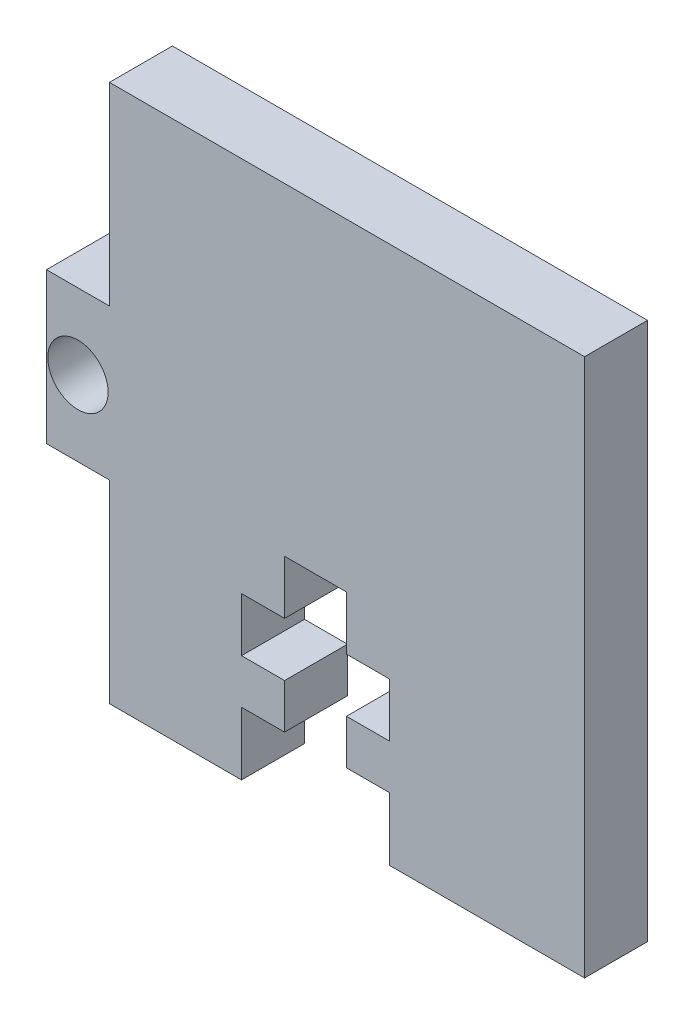
from build123d import *

# Parameters (mm, degrees)
SKETCH1_R           = 1.4224
BOSS_EXTRUDE1_DEPTH = 2.9718


with BuildPart() as part:
    # Sketch1 → Boss-Extrude1 (new body)
    with BuildSketch(Plane.XY):
        Polygon((25.4, 25.4), (2.9718, 25.4), (2.9718, 16.256), (0, 16.256), (0, 9.144), (2.9718, 9.144), (2.9718, 0), (9.2075, 0), (9.2075, 2.9718), (11.2395, 2.9718), (11.2395, 5.08), (9.2075, 5.08), (9.2075, 7.62), (11.2395, 7.62), (11.2395, 10.16), (14.1605, 10.16), (14.1605, 7.62), (16.1925, 7.62), (16.1925, 5.08), (14.1605, 5.08), (14.1605, 2.9718), (16.1925, 2.9718), (16.1925, 0), (25.4, 0), align=None)
        with Locations((1.4859, 12.7)):
            Circle(SKETCH1_R, mode=Mode.SUBTRACT)
    extrude(amount=BOSS_EXTRUDE1_DEPTH)


solid = part.part
